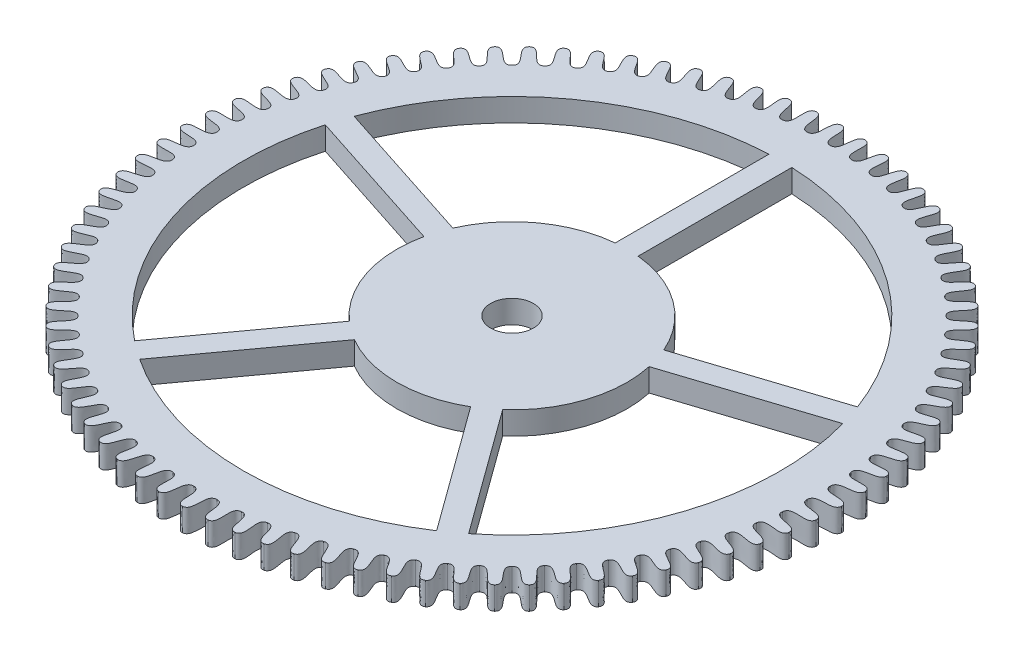
from build123d import *

# Parameters (mm, degrees)
BOSS_EXTRUDE1_84_TEETH_DEPTH = 0.3
CUT_EXTRUDE2_REACH           = 2.3
CUT_EXTRUDE3_REACH           = 2.3
SKETCH4_R                    = 0.28


with BuildPart() as part:
    # Sketch1 → Boss-Extrude1 (84 teeth) (new body)
    with BuildSketch(Plane(origin=(0, 0, 0), x_dir=(1, 0, 0), z_dir=(0, 1, 0))):
        with BuildLine():
            add(Edge.make_bspline(
                [(0, 4.315), (0.13525823, 4.312877026), (0.00799966, 4.016650924), (0.150125645, 4.01219233)],
                knots=[0, 0, 0, 0, 1, 1, 1, 1], degree=3))
            add(Edge.make_bspline(
                [(0.322460354, 4.302934385), (0.187421683, 4.310925207), (0.292187408, 4.006017369), (0.150125645, 4.01219233)],
                knots=[0, 0, 0, 0, 1, 1, 1, 1], degree=3))
            add(Edge.make_bspline(
                [(0.322460354, 4.302934385), (0.457181725, 4.290709487), (0.308141991, 4.004821739), (0.449537372, 3.989754523)],
                knots=[0, 0, 0, 0, 1, 1, 1, 1], degree=3))
            add(Edge.make_bspline(
                [(0.643117379, 4.266805015), (0.509053458, 4.284864946), (0.590740446, 3.97298054), (0.449537372, 3.989754523)],
                knots=[0, 0, 0, 0, 1, 1, 1, 1], degree=3))
            add(Edge.make_bspline(
                [(0.643117379, 4.266805015), (0.776548473, 4.24454656), (0.606561066, 3.970595965), (0.746435103, 3.94500439)],
                knots=[0, 0, 0, 0, 1, 1, 1, 1], degree=3))
            add(Edge.make_bspline(
                [(0.96017783, 4.206813941), (0.8278384, 4.234841982), (0.885989824, 3.917725192), (0.746435103, 3.94500439)],
                knots=[0, 0, 0, 0, 1, 1, 1, 1], degree=3))
            add(Edge.make_bspline(
                [(0.96017783, 4.206813941), (1.091572448, 4.174646407), (0.901588007, 3.914165008), (1.039158466, 3.878192193)],
                knots=[0, 0, 0, 0, 1, 1, 1, 1], degree=3))
            add(Edge.make_bspline(
                [(1.271868578, 4.123296657), (1.141993733, 4.161136064), (1.176284387, 3.840560335), (1.039158466, 3.878192193)],
                knots=[0, 0, 0, 0, 1, 1, 1, 1], degree=3))
            add(Edge.make_bspline(
                [(1.271868578, 4.123296657), (1.400491907, 4.081399938), (1.191572901, 3.835844453), (1.326070434, 3.789691571)],
                knots=[0, 0, 0, 0, 1, 1, 1, 1], degree=3))
            add(Edge.make_bspline(
                [(1.57644652, 4.016720225), (1.449762575, 4.064159385), (1.46000069, 3.741917507), (1.326070434, 3.789691571)],
                knots=[0, 0, 0, 0, 1, 1, 1, 1], degree=3))
            add(Edge.make_bspline(
                [(1.57644652, 4.016720225), (1.701579247, 3.965328624), (1.474894037, 3.736072299), (1.605566478, 3.679997457)],
                knots=[0, 0, 0, 0, 1, 1, 1, 1], degree=3))
            add(Edge.make_bspline(
                [(1.872208334, 3.887680665), (1.749423756, 3.944454278), (1.735552077, 3.622348358), (1.605566478, 3.679997457)],
                knots=[0, 0, 0, 0, 1, 1, 1, 1], degree=3))
            add(Edge.make_bspline(
                [(1.872208334, 3.887680665), (1.993150665, 3.827081585), (1.749966966, 3.615406514), (1.876083543, 3.549723305)],
                knots=[0, 0, 0, 0, 1, 1, 1, 1], degree=3))
            add(Edge.make_bspline(
                [(2.1575, 3.736899617), (2.03930145, 3.802690183), (2.001397554, 3.482521569), (1.876083543, 3.549723305)],
                knots=[0, 0, 0, 0, 1, 1, 1, 1], degree=3))
            add(Edge.make_bspline(
                [(2.1575, 3.736899617), (2.273575577, 3.667431953), (2.015253371, 3.474521909), (2.136108787, 3.39959766)],
                knots=[0, 0, 0, 0, 1, 1, 1, 1], degree=3))
            add(Edge.make_bspline(
                [(2.430726051, 3.565220311), (2.317774542, 3.639659902), (2.256050403, 3.323219105), (2.136108787, 3.39959766)],
                knots=[0, 0, 0, 0, 1, 1, 1, 1], degree=3))
            add(Edge.make_bspline(
                [(2.430726051, 3.565220311), (2.541285731, 3.487272554), (2.269269661, 3.314206368), (2.384188045, 3.230460086)],
                knots=[0, 0, 0, 0, 1, 1, 1, 1], degree=3))
            add(Edge.make_bspline(
                [(2.690358495, 3.373602847), (2.5832857, 3.456275166), (2.498086503, 3.145331853), (2.384188045, 3.230460086)],
                knots=[0, 0, 0, 0, 1, 1, 1, 1], degree=3))
            add(Edge.make_bspline(
                [(2.690358495, 3.373602847), (2.794783985, 3.287610912), (2.510595275, 3.135356441), (2.618933956, 3.043256468)],
                knots=[0, 0, 0, 0, 1, 1, 1, 1], degree=3))
            add(Edge.make_bspline(
                [(2.934945363, 3.163118827), (2.834350076, 3.253561538), (2.72615229, 2.949854629), (2.618933956, 3.043256468)],
                knots=[0, 0, 0, 0, 1, 1, 1, 1], degree=3))
            add(Edge.make_bspline(
                [(2.934945363, 3.163118827), (3.032652673, 3.069563616), (2.737880622, 2.938972328), (2.839033726, 2.839033726)],
                knots=[0, 0, 0, 0, 1, 1, 1, 1], degree=3))
            add(Edge.make_bspline(
                [(3.163118827, 2.934945363), (3.069563616, 3.032652673), (2.938972328, 2.737880622), (2.839033726, 2.839033726)],
                knots=[0, 0, 0, 0, 1, 1, 1, 1], degree=3))
            add(Edge.make_bspline(
                [(3.163118827, 2.934945363), (3.253561538, 2.834350076), (2.949854629, 2.72615229), (3.043256468, 2.618933956)],
                knots=[0, 0, 0, 0, 1, 1, 1, 1], degree=3))
            add(Edge.make_bspline(
                [(3.373602847, 2.690358495), (3.287610912, 2.794783985), (3.135356441, 2.510595275), (3.043256468, 2.618933956)],
                knots=[0, 0, 0, 0, 1, 1, 1, 1], degree=3))
            add(Edge.make_bspline(
                [(3.373602847, 2.690358495), (3.456275166, 2.5832857), (3.145331853, 2.498086503), (3.230460086, 2.384188045)],
                knots=[0, 0, 0, 0, 1, 1, 1, 1], degree=3))
            add(Edge.make_bspline(
                [(3.565220311, 2.430726051), (3.487272554, 2.541285731), (3.314206368, 2.269269661), (3.230460086, 2.384188045)],
                knots=[0, 0, 0, 0, 1, 1, 1, 1], degree=3))
            add(Edge.make_bspline(
                [(3.565220311, 2.430726051), (3.639659902, 2.317774542), (3.323219105, 2.256050403), (3.39959766, 2.136108787)],
                knots=[0, 0, 0, 0, 1, 1, 1, 1], degree=3))
            add(Edge.make_bspline(
                [(3.736899617, 2.1575), (3.667431953, 2.273575577), (3.474521909, 2.015253371), (3.39959766, 2.136108787)],
                knots=[0, 0, 0, 0, 1, 1, 1, 1], degree=3))
            add(Edge.make_bspline(
                [(3.736899617, 2.1575), (3.802690183, 2.03930145), (3.482521569, 2.001397554), (3.549723305, 1.876083543)],
                knots=[0, 0, 0, 0, 1, 1, 1, 1], degree=3))
            add(Edge.make_bspline(
                [(3.887680665, 1.872208334), (3.827081585, 1.993150665), (3.615406514, 1.749966966), (3.549723305, 1.876083543)],
                knots=[0, 0, 0, 0, 1, 1, 1, 1], degree=3))
            add(Edge.make_bspline(
                [(3.887680665, 1.872208334), (3.944454278, 1.749423756), (3.622348358, 1.735552077), (3.679997457, 1.605566478)],
                knots=[0, 0, 0, 0, 1, 1, 1, 1], degree=3))
            add(Edge.make_bspline(
                [(4.016720225, 1.57644652), (3.965328624, 1.701579247), (3.736072299, 1.474894037), (3.679997457, 1.605566478)],
                knots=[0, 0, 0, 0, 1, 1, 1, 1], degree=3))
            add(Edge.make_bspline(
                [(4.016720225, 1.57644652), (4.064159385, 1.449762575), (3.741917507, 1.46000069), (3.789691571, 1.326070434)],
                knots=[0, 0, 0, 0, 1, 1, 1, 1], degree=3))
            add(Edge.make_bspline(
                [(4.123296657, 1.271868578), (4.081399938, 1.400491907), (3.835844453, 1.191572901), (3.789691571, 1.326070434)],
                knots=[0, 0, 0, 0, 1, 1, 1, 1], degree=3))
            add(Edge.make_bspline(
                [(4.123296657, 1.271868578), (4.161136064, 1.141993733), (3.840560335, 1.176284387), (3.878192193, 1.039158466)],
                knots=[0, 0, 0, 0, 1, 1, 1, 1], degree=3))
            add(Edge.make_bspline(
                [(4.206813941, 0.96017783), (4.174646407, 1.091572448), (3.914165008, 0.901588007), (3.878192193, 1.039158466)],
                knots=[0, 0, 0, 0, 1, 1, 1, 1], degree=3))
            add(Edge.make_bspline(
                [(4.206813941, 0.96017783), (4.234841982, 0.8278384), (3.917725192, 0.885989824), (3.94500439, 0.746435103)],
                knots=[0, 0, 0, 0, 1, 1, 1, 1], degree=3))
            add(Edge.make_bspline(
                [(4.266805015, 0.643117379), (4.24454656, 0.776548473), (3.970595965, 0.606561066), (3.94500439, 0.746435103)],
                knots=[0, 0, 0, 0, 1, 1, 1, 1], degree=3))
            add(Edge.make_bspline(
                [(4.266805015, 0.643117379), (4.284864946, 0.509053458), (3.97298054, 0.590740446), (3.989754523, 0.449537372)],
                knots=[0, 0, 0, 0, 1, 1, 1, 1], degree=3))
            add(Edge.make_bspline(
                [(4.302934385, 0.322460354), (4.290709487, 0.457181725), (4.004821739, 0.308141991), (3.989754523, 0.449537372)],
                knots=[0, 0, 0, 0, 1, 1, 1, 1], degree=3))
            add(Edge.make_bspline(
                [(4.302934385, 0.322460354), (4.310925207, 0.187421683), (4.006017369, 0.292187408), (4.01219233, 0.150125645)],
                knots=[0, 0, 0, 0, 1, 1, 1, 1], degree=3))
            add(Edge.make_bspline(
                [(4.315, 0), (4.312877026, 0.13525823), (4.016650924, 0.00799966), (4.01219233, 0.150125645)],
                knots=[0, 0, 0, 0, 1, 1, 1, 1], degree=3))
            add(Edge.make_bspline(
                [(4.315, 0), (4.312877026, -0.13525823), (4.016650924, -0.00799966), (4.01219233, -0.150125645)],
                knots=[0, 0, 0, 0, 1, 1, 1, 1], degree=3))
            add(Edge.make_bspline(
                [(4.302934385, -0.322460354), (4.310925207, -0.187421683), (4.006017369, -0.292187408), (4.01219233, -0.150125645)],
                knots=[0, 0, 0, 0, 1, 1, 1, 1], degree=3))
            add(Edge.make_bspline(
                [(4.302934385, -0.322460354), (4.290709487, -0.457181725), (4.004821739, -0.308141991), (3.989754523, -0.449537372)],
                knots=[0, 0, 0, 0, 1, 1, 1, 1], degree=3))
            add(Edge.make_bspline(
                [(4.266805015, -0.643117379), (4.284864946, -0.509053458), (3.97298054, -0.590740446), (3.989754523, -0.449537372)],
                knots=[0, 0, 0, 0, 1, 1, 1, 1], degree=3))
            add(Edge.make_bspline(
                [(4.266805015, -0.643117379), (4.24454656, -0.776548473), (3.970595965, -0.606561066), (3.94500439, -0.746435103)],
                knots=[0, 0, 0, 0, 1, 1, 1, 1], degree=3))
            add(Edge.make_bspline(
                [(4.206813941, -0.96017783), (4.234841982, -0.8278384), (3.917725192, -0.885989824), (3.94500439, -0.746435103)],
                knots=[0, 0, 0, 0, 1, 1, 1, 1], degree=3))
            add(Edge.make_bspline(
                [(4.206813941, -0.96017783), (4.174646407, -1.091572448), (3.914165008, -0.901588007), (3.878192193, -1.039158466)],
                knots=[0, 0, 0, 0, 1, 1, 1, 1], degree=3))
            add(Edge.make_bspline(
                [(4.123296657, -1.271868578), (4.161136064, -1.141993733), (3.840560335, -1.176284387), (3.878192193, -1.039158466)],
                knots=[0, 0, 0, 0, 1, 1, 1, 1], degree=3))
            add(Edge.make_bspline(
                [(4.123296657, -1.271868578), (4.081399938, -1.400491907), (3.835844453, -1.191572901), (3.789691571, -1.326070434)],
                knots=[0, 0, 0, 0, 1, 1, 1, 1], degree=3))
            add(Edge.make_bspline(
                [(4.016720225, -1.57644652), (4.064159385, -1.449762575), (3.741917507, -1.46000069), (3.789691571, -1.326070434)],
                knots=[0, 0, 0, 0, 1, 1, 1, 1], degree=3))
            add(Edge.make_bspline(
                [(4.016720225, -1.57644652), (3.965328624, -1.701579247), (3.736072299, -1.474894037), (3.679997457, -1.605566478)],
                knots=[0, 0, 0, 0, 1, 1, 1, 1], degree=3))
            add(Edge.make_bspline(
                [(3.887680665, -1.872208334), (3.944454278, -1.749423756), (3.622348358, -1.735552077), (3.679997457, -1.605566478)],
                knots=[0, 0, 0, 0, 1, 1, 1, 1], degree=3))
            add(Edge.make_bspline(
                [(3.887680665, -1.872208334), (3.827081585, -1.993150665), (3.615406514, -1.749966966), (3.549723305, -1.876083543)],
                knots=[0, 0, 0, 0, 1, 1, 1, 1], degree=3))
            add(Edge.make_bspline(
                [(3.736899617, -2.1575), (3.802690183, -2.03930145), (3.482521569, -2.001397554), (3.549723305, -1.876083543)],
                knots=[0, 0, 0, 0, 1, 1, 1, 1], degree=3))
            add(Edge.make_bspline(
                [(3.736899617, -2.1575), (3.667431953, -2.273575577), (3.474521909, -2.015253371), (3.39959766, -2.136108787)],
                knots=[0, 0, 0, 0, 1, 1, 1, 1], degree=3))
            add(Edge.make_bspline(
                [(3.565220311, -2.430726051), (3.639659902, -2.317774542), (3.323219105, -2.256050403), (3.39959766, -2.136108787)],
                knots=[0, 0, 0, 0, 1, 1, 1, 1], degree=3))
            add(Edge.make_bspline(
                [(3.565220311, -2.430726051), (3.487272554, -2.541285731), (3.314206368, -2.269269661), (3.230460086, -2.384188045)],
                knots=[0, 0, 0, 0, 1, 1, 1, 1], degree=3))
            add(Edge.make_bspline(
                [(3.373602847, -2.690358495), (3.456275166, -2.5832857), (3.145331853, -2.498086503), (3.230460086, -2.384188045)],
                knots=[0, 0, 0, 0, 1, 1, 1, 1], degree=3))
            add(Edge.make_bspline(
                [(3.373602847, -2.690358495), (3.287610912, -2.794783985), (3.135356441, -2.510595275), (3.043256468, -2.618933956)],
                knots=[0, 0, 0, 0, 1, 1, 1, 1], degree=3))
            add(Edge.make_bspline(
                [(3.163118827, -2.934945363), (3.253561538, -2.834350076), (2.949854629, -2.72615229), (3.043256468, -2.618933956)],
                knots=[0, 0, 0, 0, 1, 1, 1, 1], degree=3))
            add(Edge.make_bspline(
                [(3.163118827, -2.934945363), (3.069563616, -3.032652673), (2.938972328, -2.737880622), (2.839033726, -2.839033726)],
                knots=[0, 0, 0, 0, 1, 1, 1, 1], degree=3))
            add(Edge.make_bspline(
                [(2.934945363, -3.163118827), (3.032652673, -3.069563616), (2.737880622, -2.938972328), (2.839033726, -2.839033726)],
                knots=[0, 0, 0, 0, 1, 1, 1, 1], degree=3))
            add(Edge.make_bspline(
                [(2.934945363, -3.163118827), (2.834350076, -3.253561538), (2.72615229, -2.949854629), (2.618933956, -3.043256468)],
                knots=[0, 0, 0, 0, 1, 1, 1, 1], degree=3))
            add(Edge.make_bspline(
                [(2.690358495, -3.373602847), (2.794783985, -3.287610912), (2.510595275, -3.135356441), (2.618933956, -3.043256468)],
                knots=[0, 0, 0, 0, 1, 1, 1, 1], degree=3))
            add(Edge.make_bspline(
                [(2.690358495, -3.373602847), (2.5832857, -3.456275166), (2.498086503, -3.145331853), (2.384188045, -3.230460086)],
                knots=[0, 0, 0, 0, 1, 1, 1, 1], degree=3))
            add(Edge.make_bspline(
                [(2.430726051, -3.565220311), (2.541285731, -3.487272554), (2.269269661, -3.314206368), (2.384188045, -3.230460086)],
                knots=[0, 0, 0, 0, 1, 1, 1, 1], degree=3))
            add(Edge.make_bspline(
                [(2.430726051, -3.565220311), (2.317774542, -3.639659902), (2.256050403, -3.323219105), (2.136108787, -3.39959766)],
                knots=[0, 0, 0, 0, 1, 1, 1, 1], degree=3))
            add(Edge.make_bspline(
                [(2.1575, -3.736899617), (2.273575577, -3.667431953), (2.015253371, -3.474521909), (2.136108787, -3.39959766)],
                knots=[0, 0, 0, 0, 1, 1, 1, 1], degree=3))
            add(Edge.make_bspline(
                [(2.1575, -3.736899617), (2.03930145, -3.802690183), (2.001397554, -3.482521569), (1.876083543, -3.549723305)],
                knots=[0, 0, 0, 0, 1, 1, 1, 1], degree=3))
            add(Edge.make_bspline(
                [(1.872208334, -3.887680665), (1.993150665, -3.827081585), (1.749966966, -3.615406514), (1.876083543, -3.549723305)],
                knots=[0, 0, 0, 0, 1, 1, 1, 1], degree=3))
            add(Edge.make_bspline(
                [(1.872208334, -3.887680665), (1.749423756, -3.944454278), (1.735552077, -3.622348358), (1.605566478, -3.679997457)],
                knots=[0, 0, 0, 0, 1, 1, 1, 1], degree=3))
            add(Edge.make_bspline(
                [(1.57644652, -4.016720225), (1.701579247, -3.965328624), (1.474894037, -3.736072299), (1.605566478, -3.679997457)],
                knots=[0, 0, 0, 0, 1, 1, 1, 1], degree=3))
            add(Edge.make_bspline(
                [(1.57644652, -4.016720225), (1.449762575, -4.064159385), (1.46000069, -3.741917507), (1.326070434, -3.789691571)],
                knots=[0, 0, 0, 0, 1, 1, 1, 1], degree=3))
            add(Edge.make_bspline(
                [(1.271868578, -4.123296657), (1.400491907, -4.081399938), (1.191572901, -3.835844453), (1.326070434, -3.789691571)],
                knots=[0, 0, 0, 0, 1, 1, 1, 1], degree=3))
            add(Edge.make_bspline(
                [(1.271868578, -4.123296657), (1.141993733, -4.161136064), (1.176284387, -3.840560335), (1.039158466, -3.878192193)],
                knots=[0, 0, 0, 0, 1, 1, 1, 1], degree=3))
            add(Edge.make_bspline(
                [(0.96017783, -4.206813941), (1.091572448, -4.174646407), (0.901588007, -3.914165008), (1.039158466, -3.878192193)],
                knots=[0, 0, 0, 0, 1, 1, 1, 1], degree=3))
            add(Edge.make_bspline(
                [(0.96017783, -4.206813941), (0.8278384, -4.234841982), (0.885989824, -3.917725192), (0.746435103, -3.94500439)],
                knots=[0, 0, 0, 0, 1, 1, 1, 1], degree=3))
            add(Edge.make_bspline(
                [(0.643117379, -4.266805015), (0.776548473, -4.24454656), (0.606561066, -3.970595965), (0.746435103, -3.94500439)],
                knots=[0, 0, 0, 0, 1, 1, 1, 1], degree=3))
            add(Edge.make_bspline(
                [(0.643117379, -4.266805015), (0.509053458, -4.284864946), (0.590740446, -3.97298054), (0.449537372, -3.989754523)],
                knots=[0, 0, 0, 0, 1, 1, 1, 1], degree=3))
            add(Edge.make_bspline(
                [(0.322460354, -4.302934385), (0.457181725, -4.290709487), (0.308141991, -4.004821739), (0.449537372, -3.989754523)],
                knots=[0, 0, 0, 0, 1, 1, 1, 1], degree=3))
            add(Edge.make_bspline(
                [(0.322460354, -4.302934385), (0.187421683, -4.310925207), (0.292187408, -4.006017369), (0.150125645, -4.01219233)],
                knots=[0, 0, 0, 0, 1, 1, 1, 1], degree=3))
            add(Edge.make_bspline(
                [(0, -4.315), (0.13525823, -4.312877026), (0.00799966, -4.016650924), (0.150125645, -4.01219233)],
                knots=[0, 0, 0, 0, 1, 1, 1, 1], degree=3))
            add(Edge.make_bspline(
                [(0, -4.315), (-0.13525823, -4.312877026), (-0.00799966, -4.016650924), (-0.150125645, -4.01219233)],
                knots=[0, 0, 0, 0, 1, 1, 1, 1], degree=3))
            add(Edge.make_bspline(
                [(-0.322460354, -4.302934385), (-0.187421683, -4.310925207), (-0.292187408, -4.006017369), (-0.150125645, -4.01219233)],
                knots=[0, 0, 0, 0, 1, 1, 1, 1], degree=3))
            add(Edge.make_bspline(
                [(-0.322460354, -4.302934385), (-0.457181725, -4.290709487), (-0.308141991, -4.004821739), (-0.449537372, -3.989754523)],
                knots=[0, 0, 0, 0, 1, 1, 1, 1], degree=3))
            add(Edge.make_bspline(
                [(-0.643117379, -4.266805015), (-0.509053458, -4.284864946), (-0.590740446, -3.97298054), (-0.449537372, -3.989754523)],
                knots=[0, 0, 0, 0, 1, 1, 1, 1], degree=3))
            add(Edge.make_bspline(
                [(-0.643117379, -4.266805015), (-0.776548473, -4.24454656), (-0.606561066, -3.970595965), (-0.746435103, -3.94500439)],
                knots=[0, 0, 0, 0, 1, 1, 1, 1], degree=3))
            add(Edge.make_bspline(
                [(-0.96017783, -4.206813941), (-0.8278384, -4.234841982), (-0.885989824, -3.917725192), (-0.746435103, -3.94500439)],
                knots=[0, 0, 0, 0, 1, 1, 1, 1], degree=3))
            add(Edge.make_bspline(
                [(-0.96017783, -4.206813941), (-1.091572448, -4.174646407), (-0.901588007, -3.914165008), (-1.039158466, -3.878192193)],
                knots=[0, 0, 0, 0, 1, 1, 1, 1], degree=3))
            add(Edge.make_bspline(
                [(-1.271868578, -4.123296657), (-1.141993733, -4.161136064), (-1.176284387, -3.840560335), (-1.039158466, -3.878192193)],
                knots=[0, 0, 0, 0, 1, 1, 1, 1], degree=3))
            add(Edge.make_bspline(
                [(-1.271868578, -4.123296657), (-1.400491907, -4.081399938), (-1.191572901, -3.835844453), (-1.326070434, -3.789691571)],
                knots=[0, 0, 0, 0, 1, 1, 1, 1], degree=3))
            add(Edge.make_bspline(
                [(-1.57644652, -4.016720225), (-1.449762575, -4.064159385), (-1.46000069, -3.741917507), (-1.326070434, -3.789691571)],
                knots=[0, 0, 0, 0, 1, 1, 1, 1], degree=3))
            add(Edge.make_bspline(
                [(-1.57644652, -4.016720225), (-1.701579247, -3.965328624), (-1.474894037, -3.736072299), (-1.605566478, -3.679997457)],
                knots=[0, 0, 0, 0, 1, 1, 1, 1], degree=3))
            add(Edge.make_bspline(
                [(-1.872208334, -3.887680665), (-1.749423756, -3.944454278), (-1.735552077, -3.622348358), (-1.605566478, -3.679997457)],
                knots=[0, 0, 0, 0, 1, 1, 1, 1], degree=3))
            add(Edge.make_bspline(
                [(-1.872208334, -3.887680665), (-1.993150665, -3.827081585), (-1.749966966, -3.615406514), (-1.876083543, -3.549723305)],
                knots=[0, 0, 0, 0, 1, 1, 1, 1], degree=3))
            add(Edge.make_bspline(
                [(-2.1575, -3.736899617), (-2.03930145, -3.802690183), (-2.001397554, -3.482521569), (-1.876083543, -3.549723305)],
                knots=[0, 0, 0, 0, 1, 1, 1, 1], degree=3))
            add(Edge.make_bspline(
                [(-2.1575, -3.736899617), (-2.273575577, -3.667431953), (-2.015253371, -3.474521909), (-2.136108787, -3.39959766)],
                knots=[0, 0, 0, 0, 1, 1, 1, 1], degree=3))
            add(Edge.make_bspline(
                [(-2.430726051, -3.565220311), (-2.317774542, -3.639659902), (-2.256050403, -3.323219105), (-2.136108787, -3.39959766)],
                knots=[0, 0, 0, 0, 1, 1, 1, 1], degree=3))
            add(Edge.make_bspline(
                [(-2.430726051, -3.565220311), (-2.541285731, -3.487272554), (-2.269269661, -3.314206368), (-2.384188045, -3.230460086)],
                knots=[0, 0, 0, 0, 1, 1, 1, 1], degree=3))
            add(Edge.make_bspline(
                [(-2.690358495, -3.373602847), (-2.5832857, -3.456275166), (-2.498086503, -3.145331853), (-2.384188045, -3.230460086)],
                knots=[0, 0, 0, 0, 1, 1, 1, 1], degree=3))
            add(Edge.make_bspline(
                [(-2.690358495, -3.373602847), (-2.794783985, -3.287610912), (-2.510595275, -3.135356441), (-2.618933956, -3.043256468)],
                knots=[0, 0, 0, 0, 1, 1, 1, 1], degree=3))
            add(Edge.make_bspline(
                [(-2.934945363, -3.163118827), (-2.834350076, -3.253561538), (-2.72615229, -2.949854629), (-2.618933956, -3.043256468)],
                knots=[0, 0, 0, 0, 1, 1, 1, 1], degree=3))
            add(Edge.make_bspline(
                [(-2.934945363, -3.163118827), (-3.032652673, -3.069563616), (-2.737880622, -2.938972328), (-2.839033726, -2.839033726)],
                knots=[0, 0, 0, 0, 1, 1, 1, 1], degree=3))
            add(Edge.make_bspline(
                [(-3.163118827, -2.934945363), (-3.069563616, -3.032652673), (-2.938972328, -2.737880622), (-2.839033726, -2.839033726)],
                knots=[0, 0, 0, 0, 1, 1, 1, 1], degree=3))
            add(Edge.make_bspline(
                [(-3.163118827, -2.934945363), (-3.253561538, -2.834350076), (-2.949854629, -2.72615229), (-3.043256468, -2.618933956)],
                knots=[0, 0, 0, 0, 1, 1, 1, 1], degree=3))
            add(Edge.make_bspline(
                [(-3.373602847, -2.690358495), (-3.287610912, -2.794783985), (-3.135356441, -2.510595275), (-3.043256468, -2.618933956)],
                knots=[0, 0, 0, 0, 1, 1, 1, 1], degree=3))
            add(Edge.make_bspline(
                [(-3.373602847, -2.690358495), (-3.456275166, -2.5832857), (-3.145331853, -2.498086503), (-3.230460086, -2.384188045)],
                knots=[0, 0, 0, 0, 1, 1, 1, 1], degree=3))
            add(Edge.make_bspline(
                [(-3.565220311, -2.430726051), (-3.487272554, -2.541285731), (-3.314206368, -2.269269661), (-3.230460086, -2.384188045)],
                knots=[0, 0, 0, 0, 1, 1, 1, 1], degree=3))
            add(Edge.make_bspline(
                [(-3.565220311, -2.430726051), (-3.639659902, -2.317774542), (-3.323219105, -2.256050403), (-3.39959766, -2.136108787)],
                knots=[0, 0, 0, 0, 1, 1, 1, 1], degree=3))
            add(Edge.make_bspline(
                [(-3.736899617, -2.1575), (-3.667431953, -2.273575577), (-3.474521909, -2.015253371), (-3.39959766, -2.136108787)],
                knots=[0, 0, 0, 0, 1, 1, 1, 1], degree=3))
            add(Edge.make_bspline(
                [(-3.736899617, -2.1575), (-3.802690183, -2.03930145), (-3.482521569, -2.001397554), (-3.549723305, -1.876083543)],
                knots=[0, 0, 0, 0, 1, 1, 1, 1], degree=3))
            add(Edge.make_bspline(
                [(-3.887680665, -1.872208334), (-3.827081585, -1.993150665), (-3.615406514, -1.749966966), (-3.549723305, -1.876083543)],
                knots=[0, 0, 0, 0, 1, 1, 1, 1], degree=3))
            add(Edge.make_bspline(
                [(-3.887680665, -1.872208334), (-3.944454278, -1.749423756), (-3.622348358, -1.735552077), (-3.679997457, -1.605566478)],
                knots=[0, 0, 0, 0, 1, 1, 1, 1], degree=3))
            add(Edge.make_bspline(
                [(-4.016720225, -1.57644652), (-3.965328624, -1.701579247), (-3.736072299, -1.474894037), (-3.679997457, -1.605566478)],
                knots=[0, 0, 0, 0, 1, 1, 1, 1], degree=3))
            add(Edge.make_bspline(
                [(-4.016720225, -1.57644652), (-4.064159385, -1.449762575), (-3.741917507, -1.46000069), (-3.789691571, -1.326070434)],
                knots=[0, 0, 0, 0, 1, 1, 1, 1], degree=3))
            add(Edge.make_bspline(
                [(-4.123296657, -1.271868578), (-4.081399938, -1.400491907), (-3.835844453, -1.191572901), (-3.789691571, -1.326070434)],
                knots=[0, 0, 0, 0, 1, 1, 1, 1], degree=3))
            add(Edge.make_bspline(
                [(-4.123296657, -1.271868578), (-4.161136064, -1.141993733), (-3.840560335, -1.176284387), (-3.878192193, -1.039158466)],
                knots=[0, 0, 0, 0, 1, 1, 1, 1], degree=3))
            add(Edge.make_bspline(
                [(-4.206813941, -0.96017783), (-4.174646407, -1.091572448), (-3.914165008, -0.901588007), (-3.878192193, -1.039158466)],
                knots=[0, 0, 0, 0, 1, 1, 1, 1], degree=3))
            add(Edge.make_bspline(
                [(-4.206813941, -0.96017783), (-4.234841982, -0.8278384), (-3.917725192, -0.885989824), (-3.94500439, -0.746435103)],
                knots=[0, 0, 0, 0, 1, 1, 1, 1], degree=3))
            add(Edge.make_bspline(
                [(-4.266805015, -0.643117379), (-4.24454656, -0.776548473), (-3.970595965, -0.606561066), (-3.94500439, -0.746435103)],
                knots=[0, 0, 0, 0, 1, 1, 1, 1], degree=3))
            add(Edge.make_bspline(
                [(-4.266805015, -0.643117379), (-4.284864946, -0.509053458), (-3.97298054, -0.590740446), (-3.989754523, -0.449537372)],
                knots=[0, 0, 0, 0, 1, 1, 1, 1], degree=3))
            add(Edge.make_bspline(
                [(-4.302934385, -0.322460354), (-4.290709487, -0.457181725), (-4.004821739, -0.308141991), (-3.989754523, -0.449537372)],
                knots=[0, 0, 0, 0, 1, 1, 1, 1], degree=3))
            add(Edge.make_bspline(
                [(-4.302934385, -0.322460354), (-4.310925207, -0.187421683), (-4.006017369, -0.292187408), (-4.01219233, -0.150125645)],
                knots=[0, 0, 0, 0, 1, 1, 1, 1], degree=3))
            add(Edge.make_bspline(
                [(-4.315, 0), (-4.312877026, -0.13525823), (-4.016650924, -0.00799966), (-4.01219233, -0.150125645)],
                knots=[0, 0, 0, 0, 1, 1, 1, 1], degree=3))
            add(Edge.make_bspline(
                [(-4.315, 0), (-4.312877026, 0.13525823), (-4.016650924, 0.00799966), (-4.01219233, 0.150125645)],
                knots=[0, 0, 0, 0, 1, 1, 1, 1], degree=3))
            add(Edge.make_bspline(
                [(-4.302934385, 0.322460354), (-4.310925207, 0.187421683), (-4.006017369, 0.292187408), (-4.01219233, 0.150125645)],
                knots=[0, 0, 0, 0, 1, 1, 1, 1], degree=3))
            add(Edge.make_bspline(
                [(-4.302934385, 0.322460354), (-4.290709487, 0.457181725), (-4.004821739, 0.308141991), (-3.989754523, 0.449537372)],
                knots=[0, 0, 0, 0, 1, 1, 1, 1], degree=3))
            add(Edge.make_bspline(
                [(-4.266805015, 0.643117379), (-4.284864946, 0.509053458), (-3.97298054, 0.590740446), (-3.989754523, 0.449537372)],
                knots=[0, 0, 0, 0, 1, 1, 1, 1], degree=3))
            add(Edge.make_bspline(
                [(-4.266805015, 0.643117379), (-4.24454656, 0.776548473), (-3.970595965, 0.606561066), (-3.94500439, 0.746435103)],
                knots=[0, 0, 0, 0, 1, 1, 1, 1], degree=3))
            add(Edge.make_bspline(
                [(-4.206813941, 0.96017783), (-4.234841982, 0.8278384), (-3.917725192, 0.885989824), (-3.94500439, 0.746435103)],
                knots=[0, 0, 0, 0, 1, 1, 1, 1], degree=3))
            add(Edge.make_bspline(
                [(-4.206813941, 0.96017783), (-4.174646407, 1.091572448), (-3.914165008, 0.901588007), (-3.878192193, 1.039158466)],
                knots=[0, 0, 0, 0, 1, 1, 1, 1], degree=3))
            add(Edge.make_bspline(
                [(-4.123296657, 1.271868578), (-4.161136064, 1.141993733), (-3.840560335, 1.176284387), (-3.878192193, 1.039158466)],
                knots=[0, 0, 0, 0, 1, 1, 1, 1], degree=3))
            add(Edge.make_bspline(
                [(-4.123296657, 1.271868578), (-4.081399938, 1.400491907), (-3.835844453, 1.191572901), (-3.789691571, 1.326070434)],
                knots=[0, 0, 0, 0, 1, 1, 1, 1], degree=3))
            add(Edge.make_bspline(
                [(-4.016720225, 1.57644652), (-4.064159385, 1.449762575), (-3.741917507, 1.46000069), (-3.789691571, 1.326070434)],
                knots=[0, 0, 0, 0, 1, 1, 1, 1], degree=3))
            add(Edge.make_bspline(
                [(-4.016720225, 1.57644652), (-3.965328624, 1.701579247), (-3.736072299, 1.474894037), (-3.679997457, 1.605566478)],
                knots=[0, 0, 0, 0, 1, 1, 1, 1], degree=3))
            add(Edge.make_bspline(
                [(-3.887680665, 1.872208334), (-3.944454278, 1.749423756), (-3.622348358, 1.735552077), (-3.679997457, 1.605566478)],
                knots=[0, 0, 0, 0, 1, 1, 1, 1], degree=3))
            add(Edge.make_bspline(
                [(-3.887680665, 1.872208334), (-3.827081585, 1.993150665), (-3.615406514, 1.749966966), (-3.549723305, 1.876083543)],
                knots=[0, 0, 0, 0, 1, 1, 1, 1], degree=3))
            add(Edge.make_bspline(
                [(-3.736899617, 2.1575), (-3.802690183, 2.03930145), (-3.482521569, 2.001397554), (-3.549723305, 1.876083543)],
                knots=[0, 0, 0, 0, 1, 1, 1, 1], degree=3))
            add(Edge.make_bspline(
                [(-3.736899617, 2.1575), (-3.667431953, 2.273575577), (-3.474521909, 2.015253371), (-3.39959766, 2.136108787)],
                knots=[0, 0, 0, 0, 1, 1, 1, 1], degree=3))
            add(Edge.make_bspline(
                [(-3.565220311, 2.430726051), (-3.639659902, 2.317774542), (-3.323219105, 2.256050403), (-3.39959766, 2.136108787)],
                knots=[0, 0, 0, 0, 1, 1, 1, 1], degree=3))
            add(Edge.make_bspline(
                [(-3.565220311, 2.430726051), (-3.487272554, 2.541285731), (-3.314206368, 2.269269661), (-3.230460086, 2.384188045)],
                knots=[0, 0, 0, 0, 1, 1, 1, 1], degree=3))
            add(Edge.make_bspline(
                [(-3.373602847, 2.690358495), (-3.456275166, 2.5832857), (-3.145331853, 2.498086503), (-3.230460086, 2.384188045)],
                knots=[0, 0, 0, 0, 1, 1, 1, 1], degree=3))
            add(Edge.make_bspline(
                [(-3.373602847, 2.690358495), (-3.287610912, 2.794783985), (-3.135356441, 2.510595275), (-3.043256468, 2.618933956)],
                knots=[0, 0, 0, 0, 1, 1, 1, 1], degree=3))
            add(Edge.make_bspline(
                [(-3.163118827, 2.934945363), (-3.253561538, 2.834350076), (-2.949854629, 2.72615229), (-3.043256468, 2.618933956)],
                knots=[0, 0, 0, 0, 1, 1, 1, 1], degree=3))
            add(Edge.make_bspline(
                [(-3.163118827, 2.934945363), (-3.069563616, 3.032652673), (-2.938972328, 2.737880622), (-2.839033726, 2.839033726)],
                knots=[0, 0, 0, 0, 1, 1, 1, 1], degree=3))
            add(Edge.make_bspline(
                [(-2.934945363, 3.163118827), (-3.032652673, 3.069563616), (-2.737880622, 2.938972328), (-2.839033726, 2.839033726)],
                knots=[0, 0, 0, 0, 1, 1, 1, 1], degree=3))
            add(Edge.make_bspline(
                [(-2.934945363, 3.163118827), (-2.834350076, 3.253561538), (-2.72615229, 2.949854629), (-2.618933956, 3.043256468)],
                knots=[0, 0, 0, 0, 1, 1, 1, 1], degree=3))
            add(Edge.make_bspline(
                [(-2.690358495, 3.373602847), (-2.794783985, 3.287610912), (-2.510595275, 3.135356441), (-2.618933956, 3.043256468)],
                knots=[0, 0, 0, 0, 1, 1, 1, 1], degree=3))
            add(Edge.make_bspline(
                [(-2.690358495, 3.373602847), (-2.5832857, 3.456275166), (-2.498086503, 3.145331853), (-2.384188045, 3.230460086)],
                knots=[0, 0, 0, 0, 1, 1, 1, 1], degree=3))
            add(Edge.make_bspline(
                [(-2.430726051, 3.565220311), (-2.541285731, 3.487272554), (-2.269269661, 3.314206368), (-2.384188045, 3.230460086)],
                knots=[0, 0, 0, 0, 1, 1, 1, 1], degree=3))
            add(Edge.make_bspline(
                [(-2.430726051, 3.565220311), (-2.317774542, 3.639659902), (-2.256050403, 3.323219105), (-2.136108787, 3.39959766)],
                knots=[0, 0, 0, 0, 1, 1, 1, 1], degree=3))
            add(Edge.make_bspline(
                [(-2.1575, 3.736899617), (-2.273575577, 3.667431953), (-2.015253371, 3.474521909), (-2.136108787, 3.39959766)],
                knots=[0, 0, 0, 0, 1, 1, 1, 1], degree=3))
            add(Edge.make_bspline(
                [(-2.1575, 3.736899617), (-2.03930145, 3.802690183), (-2.001397554, 3.482521569), (-1.876083543, 3.549723305)],
                knots=[0, 0, 0, 0, 1, 1, 1, 1], degree=3))
            add(Edge.make_bspline(
                [(-1.872208334, 3.887680665), (-1.993150665, 3.827081585), (-1.749966966, 3.615406514), (-1.876083543, 3.549723305)],
                knots=[0, 0, 0, 0, 1, 1, 1, 1], degree=3))
            add(Edge.make_bspline(
                [(-1.872208334, 3.887680665), (-1.749423756, 3.944454278), (-1.735552077, 3.622348358), (-1.605566478, 3.679997457)],
                knots=[0, 0, 0, 0, 1, 1, 1, 1], degree=3))
            add(Edge.make_bspline(
                [(-1.57644652, 4.016720225), (-1.701579247, 3.965328624), (-1.474894037, 3.736072299), (-1.605566478, 3.679997457)],
                knots=[0, 0, 0, 0, 1, 1, 1, 1], degree=3))
            add(Edge.make_bspline(
                [(-1.57644652, 4.016720225), (-1.449762575, 4.064159385), (-1.46000069, 3.741917507), (-1.326070434, 3.789691571)],
                knots=[0, 0, 0, 0, 1, 1, 1, 1], degree=3))
            add(Edge.make_bspline(
                [(-1.271868578, 4.123296657), (-1.400491907, 4.081399938), (-1.191572901, 3.835844453), (-1.326070434, 3.789691571)],
                knots=[0, 0, 0, 0, 1, 1, 1, 1], degree=3))
            add(Edge.make_bspline(
                [(-1.271868578, 4.123296657), (-1.141993733, 4.161136064), (-1.176284387, 3.840560335), (-1.039158466, 3.878192193)],
                knots=[0, 0, 0, 0, 1, 1, 1, 1], degree=3))
            add(Edge.make_bspline(
                [(-0.96017783, 4.206813941), (-1.091572448, 4.174646407), (-0.901588007, 3.914165008), (-1.039158466, 3.878192193)],
                knots=[0, 0, 0, 0, 1, 1, 1, 1], degree=3))
            add(Edge.make_bspline(
                [(-0.96017783, 4.206813941), (-0.8278384, 4.234841982), (-0.885989824, 3.917725192), (-0.746435103, 3.94500439)],
                knots=[0, 0, 0, 0, 1, 1, 1, 1], degree=3))
            add(Edge.make_bspline(
                [(-0.643117379, 4.266805015), (-0.776548473, 4.24454656), (-0.606561066, 3.970595965), (-0.746435103, 3.94500439)],
                knots=[0, 0, 0, 0, 1, 1, 1, 1], degree=3))
            add(Edge.make_bspline(
                [(-0.643117379, 4.266805015), (-0.509053458, 4.284864946), (-0.590740446, 3.97298054), (-0.449537372, 3.989754523)],
                knots=[0, 0, 0, 0, 1, 1, 1, 1], degree=3))
            add(Edge.make_bspline(
                [(-0.322460354, 4.302934385), (-0.457181725, 4.290709487), (-0.308141991, 4.004821739), (-0.449537372, 3.989754523)],
                knots=[0, 0, 0, 0, 1, 1, 1, 1], degree=3))
            add(Edge.make_bspline(
                [(-0.322460354, 4.302934385), (-0.187421683, 4.310925207), (-0.292187408, 4.006017369), (-0.150125645, 4.01219233)],
                knots=[0, 0, 0, 0, 1, 1, 1, 1], degree=3))
            add(Edge.make_bspline(
                [(0, 4.315), (-0.13525823, 4.312877026), (-0.00799966, 4.016650924), (-0.150125645, 4.01219233)],
                knots=[0, 0, 0, 0, 1, 1, 1, 1], degree=3))
        make_face()
    extrude(amount=BOSS_EXTRUDE1_84_TEETH_DEPTH)

    # Sketch3 → Cut-Extrude2 (cut, up to next)
    with BuildSketch(Plane(origin=(0, 0, 0), x_dir=(1, 0, 0), z_dir=(0, 1, 0)), mode=Mode.PRIVATE) as cut_extrude2_sk1:
        with BuildLine():
            Line((-0.15, 3.511797973), (-0.15, 1.500521243))
            ThreePointArc((-0.15, 1.500521243), (-0.88638016, 1.219997628), (-1.380727957, 0.606345042))
            Line((-1.380727957, 0.606345042), (-3.293565797, 1.227863732))
            ThreePointArc((-3.293565797, 1.227863732), (-2.066065162, 2.843694735), (-0.15, 3.511797973))
        make_face()
    cut_extrude2_tool1 = extrude(cut_extrude2_sk1.sketch, amount=CUT_EXTRUDE2_REACH, mode=Mode.PRIVATE) & part.part
    add(cut_extrude2_tool1.solids().sort_by_distance((-1.479198, 0, -2.035942))[0], mode=Mode.SUBTRACT)
    # Sketch3 → Cut-Extrude2 (cut, up to next)
    with BuildSketch(Plane(origin=(0, 0, 0), x_dir=(1, 0, 0), z_dir=(0, 1, 0)), mode=Mode.PRIVATE) as cut_extrude2_sk2:
        with BuildLine():
            Line((3.293565797, 1.227863732), (1.380727957, 0.606345042))
            ThreePointArc((1.380727957, 0.606345042), (0.88638016, 1.219997628), (0.15, 1.500521243))
            Line((0.15, 1.500521243), (0.15, 3.511797973))
            ThreePointArc((0.15, 3.511797973), (2.066065162, 2.843694735), (3.293565797, 1.227863732))
        make_face()
    cut_extrude2_tool2 = extrude(cut_extrude2_sk2.sketch, amount=CUT_EXTRUDE2_REACH, mode=Mode.PRIVATE) & part.part
    add(cut_extrude2_tool2.solids().sort_by_distance((1.479198, 0, -2.035942))[0], mode=Mode.SUBTRACT)
    # Sketch3 → Cut-Extrude2 (cut, up to next)
    with BuildSketch(Plane(origin=(0, 0, 0), x_dir=(1, 0, 0), z_dir=(0, 1, 0)), mode=Mode.PRIVATE) as cut_extrude2_sk3:
        with BuildLine():
            Line((1.473433055, 0.321028087), (3.386270895, 0.942546777))
            ThreePointArc((3.386270895, 0.942546777), (3.342963655, -1.086194735), (2.185535606, -2.752936453))
            Line((2.185535606, -2.752936453), (1.003336806, -1.125779398))
            ThreePointArc((1.003336806, -1.125779398), (1.434193227, -0.465997628), (1.473433055, 0.321028087))
        make_face()
    cut_extrude2_tool3 = extrude(cut_extrude2_sk3.sketch, amount=CUT_EXTRUDE2_REACH, mode=Mode.PRIVATE) & part.part
    add(cut_extrude2_tool3.solids().sort_by_distance((2.393393, 0, 0.777661))[0], mode=Mode.SUBTRACT)
    # Sketch3 → Cut-Extrude2 (cut, up to next)
    with BuildSketch(Plane(origin=(0, 0, 0), x_dir=(1, 0, 0), z_dir=(0, 1, 0)), mode=Mode.PRIVATE) as cut_extrude2_sk4:
        with BuildLine():
            Line((0.760631708, -1.302114974), (1.942830508, -2.929272028))
            ThreePointArc((1.942830508, -2.929272028), (0, -3.515), (-1.942830508, -2.929272028))
            Line((-1.942830508, -2.929272028), (-0.760631708, -1.302114974))
            ThreePointArc((-0.760631708, -1.302114974), (0, -1.508), (0.760631708, -1.302114974))
        make_face()
    cut_extrude2_tool4 = extrude(cut_extrude2_sk4.sketch, amount=CUT_EXTRUDE2_REACH, mode=Mode.PRIVATE) & part.part
    add(cut_extrude2_tool4.solids().sort_by_distance((0, 0, 2.516563))[0], mode=Mode.SUBTRACT)
    # Sketch3 → Cut-Extrude2 (cut, up to next)
    with BuildSketch(Plane(origin=(0, 0, 0), x_dir=(1, 0, 0), z_dir=(0, 1, 0)), mode=Mode.PRIVATE) as cut_extrude2_sk5:
        with BuildLine():
            Line((-1.003336806, -1.125779398), (-2.185535606, -2.752936453))
            ThreePointArc((-2.185535606, -2.752936453), (-3.342963655, -1.086194735), (-3.386270895, 0.942546777))
            Line((-3.386270895, 0.942546777), (-1.473433055, 0.321028087))
            ThreePointArc((-1.473433055, 0.321028087), (-1.434193227, -0.465997628), (-1.003336806, -1.125779398))
        make_face()
    cut_extrude2_tool5 = extrude(cut_extrude2_sk5.sketch, amount=CUT_EXTRUDE2_REACH, mode=Mode.PRIVATE) & part.part
    add(cut_extrude2_tool5.solids().sort_by_distance((-2.393393, 0, 0.777661))[0], mode=Mode.SUBTRACT)

    # Sketch4 → Cut-Extrude3 (cut, up to next)
    with BuildSketch(Plane(origin=(0, 0, 0), x_dir=(1, 0, 0), z_dir=(0, 1, 0)), mode=Mode.PRIVATE) as cut_extrude3_sk1:
        Circle(SKETCH4_R)
    cut_extrude3_tool1 = extrude(cut_extrude3_sk1.sketch, amount=CUT_EXTRUDE3_REACH, mode=Mode.PRIVATE) & part.part
    add(cut_extrude3_tool1.solids().sort_by_distance((0, 0, 0))[0], mode=Mode.SUBTRACT)


solid = part.part
